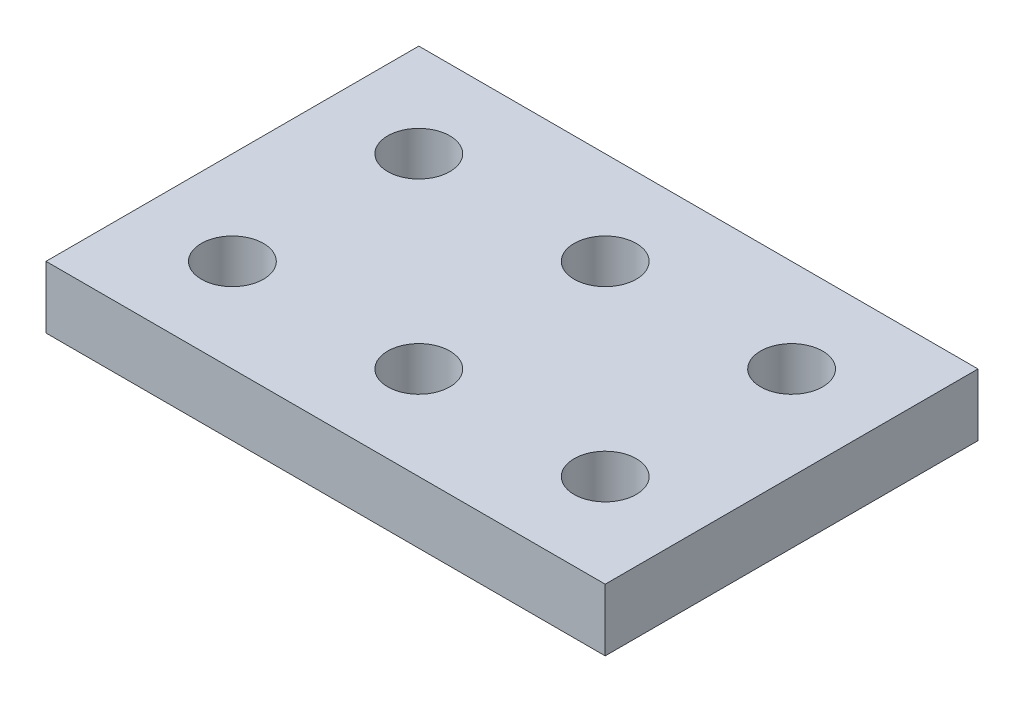
from build123d import *

# Parameters (mm, degrees)
SKETCH1_W           = 90
SKETCH1_H           = 60
SKETCH1_R           = 5
BOSS_EXTRUDE1_DEPTH = 10


with BuildPart() as part:
    # Sketch1 → Boss-Extrude1 (new body)
    with BuildSketch(Plane(origin=(0, 0, 0), x_dir=(1, 0, 0), z_dir=(0, 1, 0))):
        with Locations((45, 30)):
            Rectangle(SKETCH1_W, SKETCH1_H)
        with Locations((15, 45)):
            Circle(SKETCH1_R, mode=Mode.SUBTRACT)
        with Locations((45, 45)):
            Circle(SKETCH1_R, mode=Mode.SUBTRACT)
        with Locations((75, 45)):
            Circle(SKETCH1_R, mode=Mode.SUBTRACT)
        with Locations((45, 15)):
            Circle(SKETCH1_R, mode=Mode.SUBTRACT)
        with Locations((75, 15)):
            Circle(SKETCH1_R, mode=Mode.SUBTRACT)
        with Locations((15, 15)):
            Circle(SKETCH1_R, mode=Mode.SUBTRACT)
    extrude(amount=BOSS_EXTRUDE1_DEPTH)


solid = part.part
